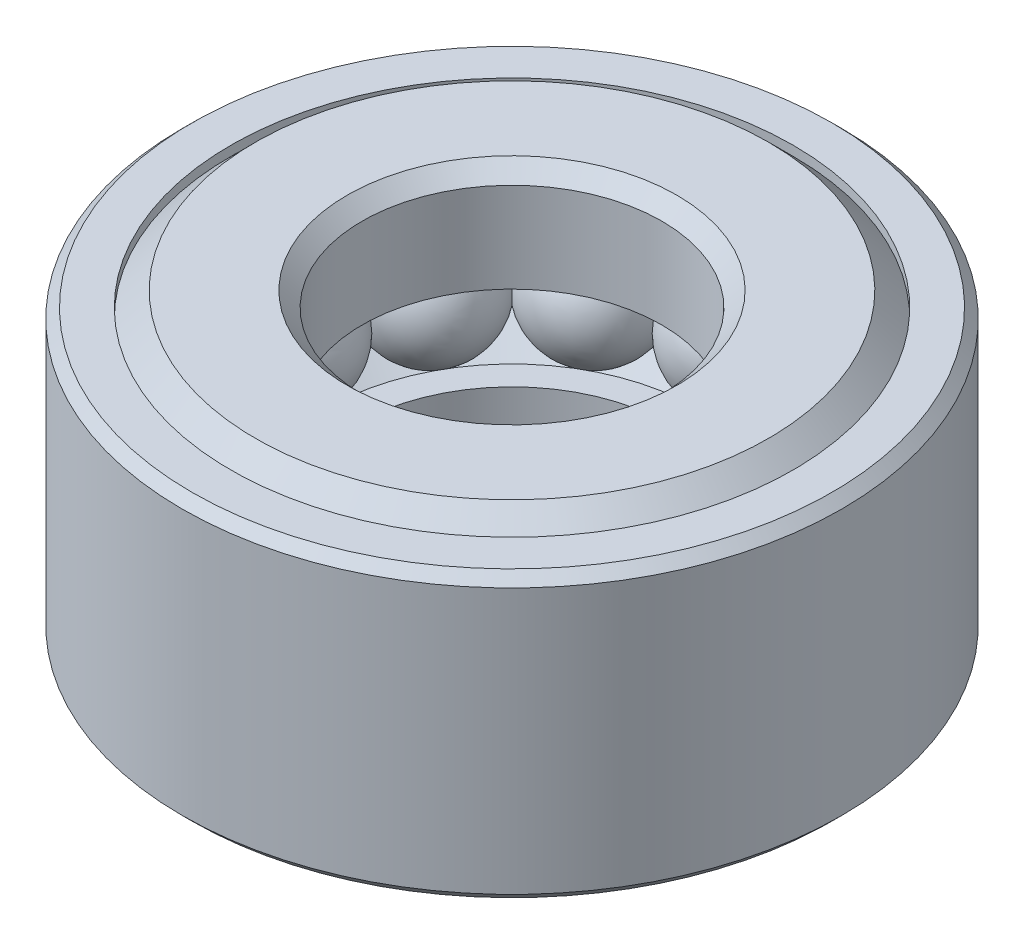
from build123d import *

# Parameters (mm, degrees)
CIRPATTERN1_COUNT = 12


with BuildPart() as part:
    # Sketch7 → Revolve4 (revolve)
    with BuildSketch(Plane(origin=(0, 0, 0), x_dir=(0, 0, -1), z_dir=(1, 0, 0))):
        Polygon((-6.794700447, 3.96875), (-4.365625, 3.96875), (-3.96875, 3.571875), (-3.96875, 1.190625), (-4.907061198, 1.190625), (-5.95709375, 2.116666667), (-7.007126302, 1.190625), (-7.9454375, 1.190625), (-7.9454375, 2.818012947), align=None)
        Polygon((-4.1656, -1.190625), (-4.907061198, -1.190625), (-5.95709375, -2.116666667), (-7.007126302, -1.190625), (-8.03275, -1.190625), (-8.03275, -3.712344075), (-7.776344075, -3.96875), (-4.562475, -3.96875), (-4.1656, -3.571875), align=None)
    revolve(axis=Axis((0, -3.96875, 0), (0, 1, 0)))


with BuildPart() as body_2:
    # Sketch3 → Revolve2 (revolve)
    with BuildSketch(Plane(origin=(0, 0, 0), x_dir=(0, 0, -1), z_dir=(1, 0, 0))):
        with BuildLine():
            Line((-5.95709375, 1.5875), (-5.95709375, -1.5875))
            ThreePointArc((-5.95709375, -1.5875), (-7.54459375, 0), (-5.95709375, 1.5875))
        make_face()
    revolve(axis=Axis((0, 1.5875, 5.95709375), (0, -1, 0)))


with BuildPart() as cirpattern1_1:
    # CirPattern1: pattern copy
    add(body_2.part.rotate(Axis((0, 0, 0), (0, 1, 0)), 1 * 360 / CIRPATTERN1_COUNT))


with BuildPart() as cirpattern1_2:
    # CirPattern1: pattern copy
    add(body_2.part.rotate(Axis((0, 0, 0), (0, 1, 0)), 2 * 360 / CIRPATTERN1_COUNT))


with BuildPart() as cirpattern1_3:
    # CirPattern1: pattern copy
    add(body_2.part.rotate(Axis((0, 0, 0), (0, 1, 0)), 3 * 360 / CIRPATTERN1_COUNT))


with BuildPart() as cirpattern1_4:
    # CirPattern1: pattern copy
    add(body_2.part.rotate(Axis((0, 0, 0), (0, 1, 0)), 4 * 360 / CIRPATTERN1_COUNT))


with BuildPart() as cirpattern1_5:
    # CirPattern1: pattern copy
    add(body_2.part.rotate(Axis((0, 0, 0), (0, 1, 0)), 5 * 360 / CIRPATTERN1_COUNT))


with BuildPart() as cirpattern1_6:
    # CirPattern1: pattern copy
    add(body_2.part.rotate(Axis((0, 0, 0), (0, 1, 0)), 6 * 360 / CIRPATTERN1_COUNT))


with BuildPart() as cirpattern1_7:
    # CirPattern1: pattern copy
    add(body_2.part.rotate(Axis((0, 0, 0), (0, 1, 0)), 7 * 360 / CIRPATTERN1_COUNT))


with BuildPart() as cirpattern1_8:
    # CirPattern1: pattern copy
    add(body_2.part.rotate(Axis((0, 0, 0), (0, 1, 0)), 8 * 360 / CIRPATTERN1_COUNT))


with BuildPart() as cirpattern1_9:
    # CirPattern1: pattern copy
    add(body_2.part.rotate(Axis((0, 0, 0), (0, 1, 0)), 9 * 360 / CIRPATTERN1_COUNT))


with BuildPart() as cirpattern1_10:
    # CirPattern1: pattern copy
    add(body_2.part.rotate(Axis((0, 0, 0), (0, 1, 0)), 10 * 360 / CIRPATTERN1_COUNT))


with BuildPart() as cirpattern1_11:
    # CirPattern1: pattern copy
    add(body_2.part.rotate(Axis((0, 0, 0), (0, 1, 0)), 11 * 360 / CIRPATTERN1_COUNT))


with BuildPart() as body_14:
    # Sketch4 → Revolve3 (revolve)
    with BuildSketch(Plane(origin=(0, 0, 0), x_dir=(0, 0, -1), z_dir=(1, 0, 0))):
        Polygon((-7.447981372, 3.315469075), (-8.03275, 3.315469075), (-8.03275, -3.96875), (-8.474844075, -3.96875), (-8.73125, -3.712344075), (-8.73125, 3.315469075), (-8.474844075, 3.571875), (-7.447981372, 3.571875), align=None)
    revolve(axis=Axis((0, -3.96875, 0), (0, 1, 0)))


solid = Compound([part.part, body_2.part, cirpattern1_1.part, cirpattern1_2.part, cirpattern1_3.part, cirpattern1_4.part, cirpattern1_5.part, cirpattern1_6.part, cirpattern1_7.part, cirpattern1_8.part, cirpattern1_9.part, cirpattern1_10.part, cirpattern1_11.part, body_14.part])
